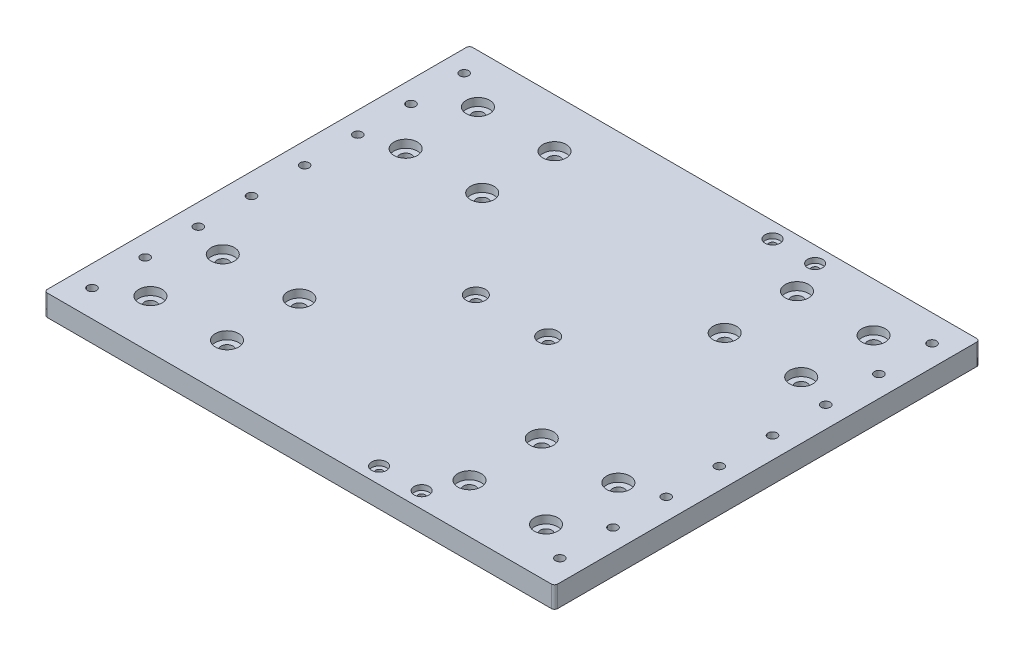
from build123d import *

# Parameters (mm, degrees)
SKETCH1_W                                        = 240
SKETCH1_H                                        = 200
BOSS_EXTRUDE1_DEPTH                              = 5
CBORE_FOR_M5_PAN_HEAD_MACHINE_SCREW1_D           = 5.5
CBORE_FOR_M5_PAN_HEAD_MACHINE_SCREW1_CBORE_D     = 11
CBORE_FOR_M5_PAN_HEAD_MACHINE_SCREW1_CBORE_DEPTH = 3.7
MIRROR2_COPY_1_D                                 = 5.5
MIRROR2_COPY_1_CBORE_D                           = 11
MIRROR2_COPY_1_CBORE_DEPTH                       = 3.7
CBORE_FOR_M4_PAN_HEAD_MACHINE_SCREW1_D           = 4.5
CBORE_FOR_M4_PAN_HEAD_MACHINE_SCREW1_CBORE_D     = 9
CBORE_FOR_M4_PAN_HEAD_MACHINE_SCREW1_CBORE_DEPTH = 3.1
M5X0_8_TAPPED_HOLE1_D                            = 4.2
FILLET1_R                                        = 1.5
LPATTERN2_COUNT                                  = 8
LPATTERN2_PITCH                                  = 25
CBORE_FOR_M3_PAN_HEAD_MACHINE_SCREW1_D           = 3.2
CBORE_FOR_M3_PAN_HEAD_MACHINE_SCREW1_CBORE_D     = 7
CBORE_FOR_M3_PAN_HEAD_MACHINE_SCREW1_CBORE_DEPTH = 2.4


with BuildPart() as part:
    # Sketch1 → Boss-Extrude1 (new body, symmetric)
    with BuildSketch(Plane(origin=(0, 0, 0), x_dir=(1, 0, 0), z_dir=(0, 1, 0))):
        Rectangle(SKETCH1_W, SKETCH1_H)
    extrude(amount=BOSS_EXTRUDE1_DEPTH, both=True)

    # CBORE for M5 Pan Head Machine Screw1 (through all)
    with Locations(Plane(origin=(66.92305649, 5, -81.969265096), x_dir=(-1, 0, 0), z_dir=(0, 1, 0))):
        with Locations((159.92305649, 158.969265096), (123.92305649, 158.969265096), (123.92305649, 124.969265096), (159.92305649, 124.969265096)):
            cbore_for_m5_pan_head_machine_screw1 = CounterBoreHole(CBORE_FOR_M5_PAN_HEAD_MACHINE_SCREW1_D / 2, CBORE_FOR_M5_PAN_HEAD_MACHINE_SCREW1_CBORE_D / 2, CBORE_FOR_M5_PAN_HEAD_MACHINE_SCREW1_CBORE_DEPTH)

    # Mirror1: CBORE for M5 Pan Head Machine Screw1 across plane
    add(cbore_for_m5_pan_head_machine_screw1.mirror(Plane(origin=(0, 0, 0), x_dir=(0, 0, 1), z_dir=(1, 0, 0))), mode=Mode.SUBTRACT)

    # Mirror2: CBORE for M5 Pan Head Machine Screw1 across plane
    add(cbore_for_m5_pan_head_machine_screw1.mirror(Plane.XY), mode=Mode.SUBTRACT)

    # Mirror2 copy 1 (through all)
    with Locations(Plane(origin=(-66.92305649, 5, 81.969265096), x_dir=(1, 0, 0), z_dir=(0, 1, 0))):
        with Locations((159.92305649, 158.969265096), (123.92305649, 158.969265096), (123.92305649, 124.969265096), (159.92305649, 124.969265096)):
            CounterBoreHole(MIRROR2_COPY_1_D / 2, MIRROR2_COPY_1_CBORE_D / 2, MIRROR2_COPY_1_CBORE_DEPTH)

    # CBORE for M4 Pan Head Machine Screw1 (through all)
    with Locations(Plane(origin=(-30.338508942, 5, -23.538498317), x_dir=(-1, 0, 0), z_dir=(0, 1, 0))):
        with Locations((-13.338508942, 23.538498317), (-47.338508942, 23.538498317)):
            CounterBoreHole(CBORE_FOR_M4_PAN_HEAD_MACHINE_SCREW1_D / 2, CBORE_FOR_M4_PAN_HEAD_MACHINE_SCREW1_CBORE_D / 2, CBORE_FOR_M4_PAN_HEAD_MACHINE_SCREW1_CBORE_DEPTH)

    # M5x0.8 Tapped Hole1 (through all)
    with Locations(Plane(origin=(0, 5, 0), x_dir=(1, 0, 0), z_dir=(0, 1, 0))):
        with Locations((-110, 87.5), (110, 87.5)):
            m5x0_8_tapped_hole1 = Hole(M5X0_8_TAPPED_HOLE1_D / 2)

    # Fillet1
    fillet1_edges = [part.edges().sort_by_distance(p)[0] for p in [
        (120, 0, 100),
        (-120, 0, 100),
        (-120, 0, -100),
        (120, 0, -100),
    ]]
    fillet(fillet1_edges, radius=FILLET1_R)

    # LPattern2: M5x0.8 Tapped Hole1 ×8
    with Locations(*[(0, 0, i * LPATTERN2_PITCH) for i in range(1, LPATTERN2_COUNT)]):
        add(m5x0_8_tapped_hole1, mode=Mode.SUBTRACT)

    # CBORE for M3 Pan Head Machine Screw1 (through all)
    with Locations(Plane(origin=(0, 5, 0), x_dir=(1, 0, 0), z_dir=(0, 1, 0))):
        with Locations((30, 92.5), (50, 92.5)):
            cbore_for_m3_pan_head_machine_screw1 = CounterBoreHole(CBORE_FOR_M3_PAN_HEAD_MACHINE_SCREW1_D / 2, CBORE_FOR_M3_PAN_HEAD_MACHINE_SCREW1_CBORE_D / 2, CBORE_FOR_M3_PAN_HEAD_MACHINE_SCREW1_CBORE_DEPTH)

    # Mirror3: CBORE for M3 Pan Head Machine Screw1 across plane
    add(cbore_for_m3_pan_head_machine_screw1.mirror(Plane.XY), mode=Mode.SUBTRACT)


solid = part.part
